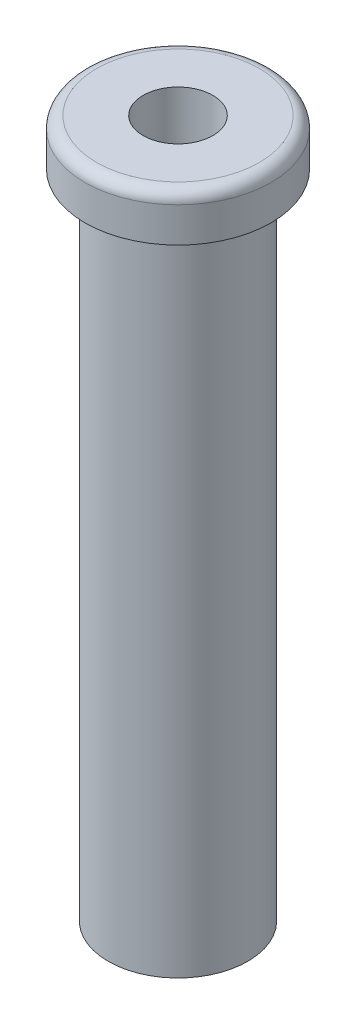
from build123d import *

# Parameters (mm, degrees)
SCHIZZO1_R                   = 6
SCHIZZO1_R_2                 = 3
ESTRUSIONE_ESTRUSIONE1_DEPTH = 56
SCHIZZO2_R                   = 8
SCHIZZO2_R_2                 = 3
ESTRUSIONE_ESTRUSIONE2_DEPTH = 4
RACCORDO1_R                  = 1


with BuildPart() as part:
    # Schizzo1 → Estrusione-Estrusione1 (new body)
    with BuildSketch(Plane(origin=(0, 0, 0), x_dir=(1, 0, 0), z_dir=(0, 1, 0))):
        Circle(SCHIZZO1_R)
        Circle(SCHIZZO1_R_2, mode=Mode.SUBTRACT)
    extrude(amount=ESTRUSIONE_ESTRUSIONE1_DEPTH)

    # Schizzo2 → Estrusione-Estrusione2 (add)
    with BuildSketch(Plane(origin=(0, 56, 0), x_dir=(1, 0, 0), z_dir=(0, 1, 0))):
        Circle(SCHIZZO2_R)
        Circle(SCHIZZO2_R_2, mode=Mode.SUBTRACT)
    extrude(amount=ESTRUSIONE_ESTRUSIONE2_DEPTH)

    # Raccordo1
    raccordo1_edges = [part.edges().sort_by_distance(p)[0] for p in [
        (-8, 60, 0),
    ]]
    fillet(raccordo1_edges, radius=RACCORDO1_R)


solid = part.part
